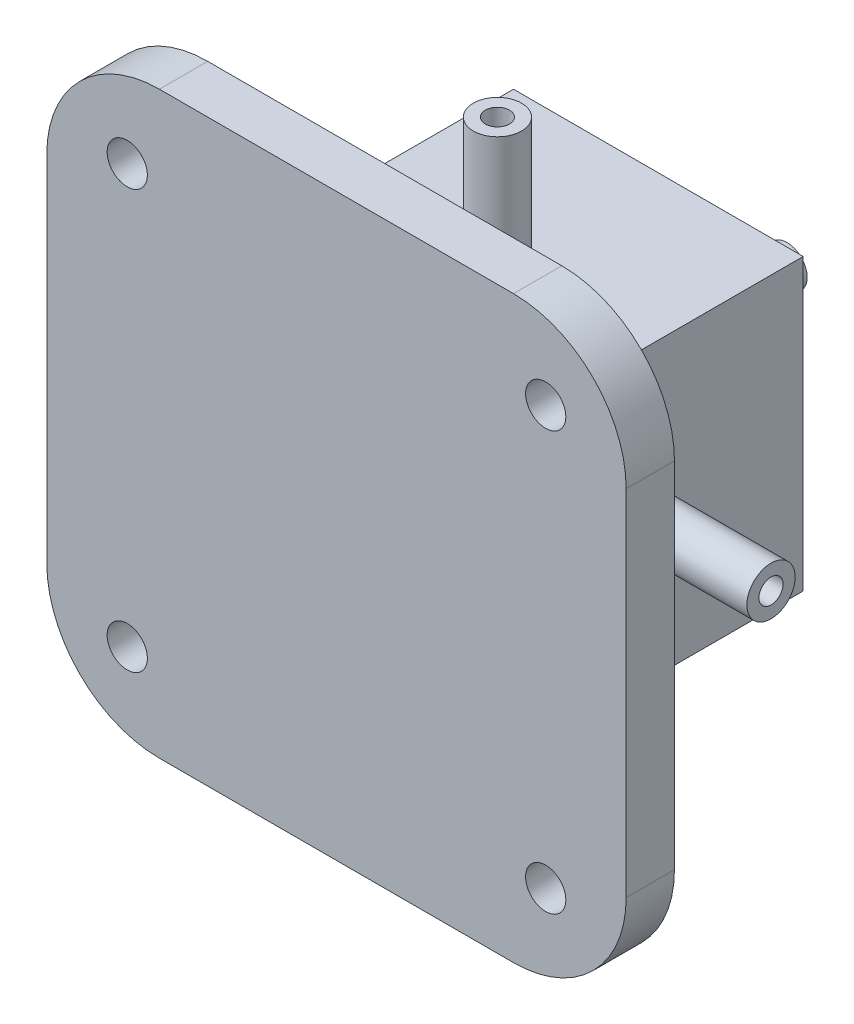
from build123d import *

# Parameters (mm, degrees)
SKETCH_1_R               = 1.25
EXTRUDE_3_DEPTH          = 3
SKETCH_2_W               = 18
SKETCH_2_H               = 18
EXTRUDE_4_DEPTH          = 17
SKETCH_3_R               = 0.85
CUT_EXTRUDE_2_DEPTH      = 12
SKETCH_4_R               = 0.75
CUT_EXTRUDE_4_DEPTH      = 18
SKETCH_5_R               = 0.75
CUT_EXTRUDE_5_DEPTH      = 18
SKETCH_6_R               = 1.5
SKETCH_6_R_2             = 0.75
EXTRUDE_7_DEPTH          = 8
SKETCH_10_R              = 1.25
SKETCH_10_R_2            = 0.85
EXTRUDE_13_DEPTH         = 8
PATTERN_CIRCULAR_1_COUNT = 4


with BuildPart() as part:
    # 草图1 → 凸台-拉伸3 (new body)
    with BuildSketch(Plane.XY):
        with BuildLine():
            Line((-11, -18), (11, -18))
            ThreePointArc((11, -18), (15.949747468, -15.949747468), (18, -11))
            Line((18, -11), (18, 11))
            ThreePointArc((18, 11), (15.949747468, 15.949747468), (11, 18))
            Line((11, 18), (-11, 18))
            ThreePointArc((-11, 18), (-15.949747468, 15.949747468), (-18, 11))
            Line((-18, 11), (-18, -11))
            ThreePointArc((-18, -11), (-15.949747468, -15.949747468), (-11, -18))
        make_face()
        with Locations((13, 13)):
            Circle(SKETCH_1_R, mode=Mode.SUBTRACT)
        with Locations((-13, 13)):
            Circle(SKETCH_1_R, mode=Mode.SUBTRACT)
        with Locations((-13, -13)):
            Circle(SKETCH_1_R, mode=Mode.SUBTRACT)
        with Locations((13, -13)):
            Circle(SKETCH_1_R, mode=Mode.SUBTRACT)
    extrude(amount=EXTRUDE_3_DEPTH)

    # 草图2 → 凸台-拉伸4 (add)
    with BuildSketch(Plane.XY):
        Rectangle(SKETCH_2_W, SKETCH_2_H)
    extrude(amount=-EXTRUDE_4_DEPTH)

    # 草图3 → 切除-拉伸2 (cut)
    with BuildSketch(Plane(origin=(0, 0, -17), x_dir=(-1, 0, 0), z_dir=(0, 0, -1))):
        Circle(SKETCH_3_R)
    extrude(amount=-CUT_EXTRUDE_2_DEPTH, mode=Mode.SUBTRACT)

    # 草图4 → 切除-拉伸4 (cut)
    with BuildSketch(Plane.ZY.offset(9)):
        with Locations((-7, 0)):
            Circle(SKETCH_4_R)
    extrude(amount=-CUT_EXTRUDE_4_DEPTH, mode=Mode.SUBTRACT)

    # 草图5 → 切除-拉伸5 (cut)
    with BuildSketch(Plane(origin=(0, 9, 0), x_dir=(1, 0, 0), z_dir=(0, 1, 0))):
        with Locations((0, 7)):
            Circle(SKETCH_5_R)
    extrude(amount=-CUT_EXTRUDE_5_DEPTH, mode=Mode.SUBTRACT)

    # 草图6 → 凸台-拉伸7 (add)
    with BuildSketch(Plane.ZY.offset(9)):
        with Locations((-7, 0)):
            Circle(SKETCH_6_R)
        with Locations((-7, 0)):
            Circle(SKETCH_6_R_2, mode=Mode.SUBTRACT)
    extrude_7 = extrude(amount=EXTRUDE_7_DEPTH)

    # 草图10 → 凸台-拉伸13 (add)
    with BuildSketch(Plane(origin=(0, 0, -17), x_dir=(-1, 0, 0), z_dir=(0, 0, -1))):
        Circle(SKETCH_10_R)
        Circle(SKETCH_10_R_2, mode=Mode.SUBTRACT)
    extrude(amount=EXTRUDE_13_DEPTH)

    # 阵列(圆周)1: 凸台-拉伸7 ×4 about axis
    pattern_circular_1_axis = Axis((0, 0, 0), (0, 0, 1))
    for i in range(1, PATTERN_CIRCULAR_1_COUNT):
        add(extrude_7.rotate(pattern_circular_1_axis, i * 360 / PATTERN_CIRCULAR_1_COUNT))


solid = part.part
